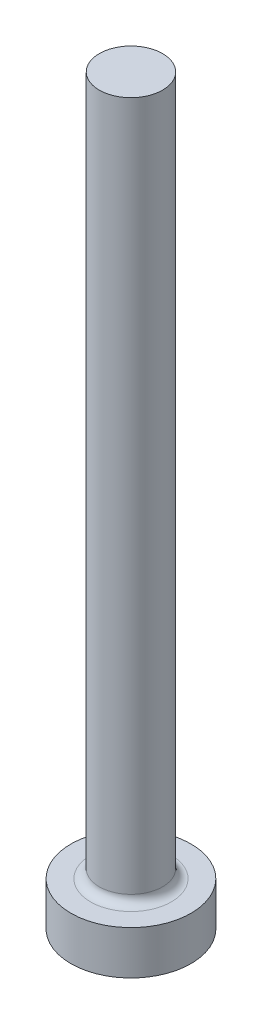
from build123d import *

# Parameters (mm, degrees)
SKETCH_1_R      = 2.75
EXTRUDE_1_DEPTH = 2
SKETCH_2_R      = 1.45
EXTRUDE_2_DEPTH = 32
FILLET_1_R      = 0.4


with BuildPart() as part:
    # 草图1 → 凸台-拉伸1 (new body)
    with BuildSketch(Plane(origin=(0, 0, 0), x_dir=(1, 0, 0), z_dir=(0, 1, 0))):
        Circle(SKETCH_1_R)
    extrude(amount=EXTRUDE_1_DEPTH)

    # 草图2 → 凸台-拉伸2 (add)
    with BuildSketch(Plane(origin=(0, 2, 0), x_dir=(1, 0, 0), z_dir=(0, 1, 0))):
        Circle(SKETCH_2_R)
    extrude(amount=EXTRUDE_2_DEPTH)

    # 圆角1
    fillet_1_edges = [part.edges().sort_by_distance(p)[0] for p in [
        (-1.45, 2, 0),
    ]]
    fillet(fillet_1_edges, radius=FILLET_1_R)


solid = part.part
